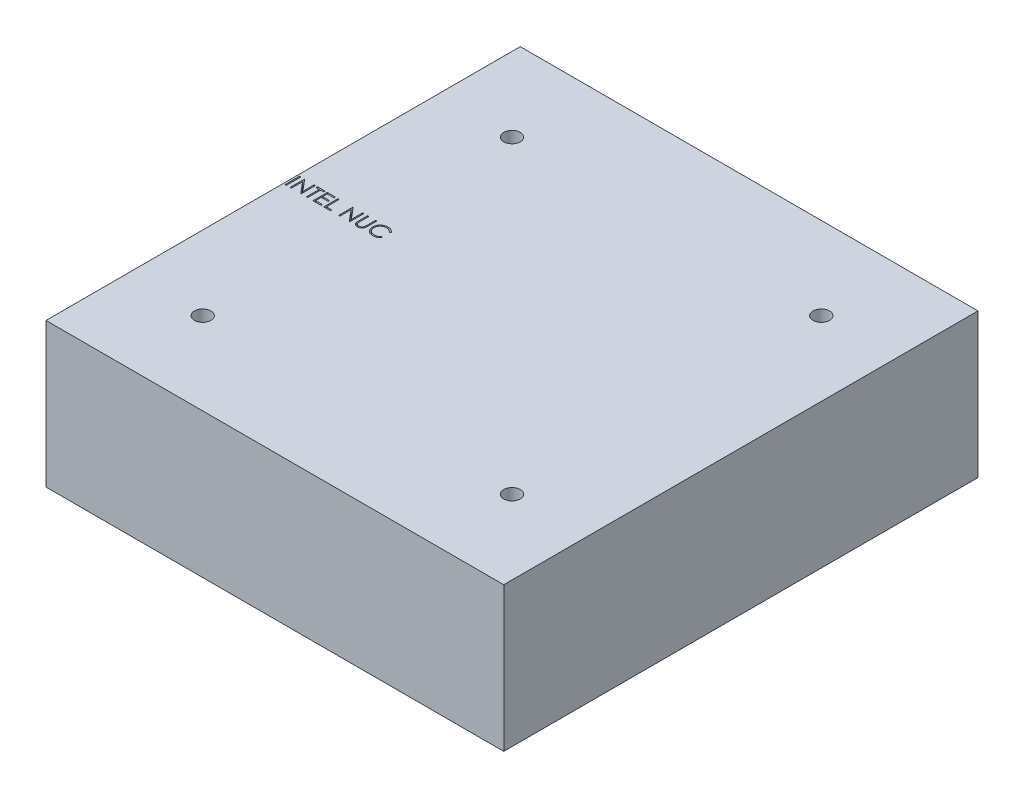
from build123d import *

# Parameters (mm, degrees)
SKETCH1_W           = 111
SKETCH1_H           = 115
BOSS_EXTRUDE1_DEPTH = 35
SKETCH2_R           = 2
CUT_EXTRUDE1_DEPTH  = 36
SKETCH3_W           = 0.314102564
SKETCH3_H           = 3.5
CUT_EXTRUDE2_DEPTH  = 36


with BuildPart() as part:
    # Sketch1 → Boss-Extrude1 (new body)
    with BuildSketch(Plane(origin=(0, 0, 0), x_dir=(1, 0, 0), z_dir=(0, 1, 0))):
        with Locations((55.5, 57.5)):
            Rectangle(SKETCH1_W, SKETCH1_H)
    extrude(amount=BOSS_EXTRUDE1_DEPTH)

    # Sketch2 → Cut-Extrude1 (cut, through all)
    with BuildSketch(Plane.XZ):
        with Locations((18, -20)):
            Circle(SKETCH2_R)
        with Locations((18, -95)):
            Circle(SKETCH2_R)
        with Locations((93, -20)):
            Circle(SKETCH2_R)
        with Locations((93, -95)):
            Circle(SKETCH2_R)
    extrude(amount=-CUT_EXTRUDE1_DEPTH, mode=Mode.SUBTRACT)

    # Sketch3 → Cut-Extrude2 (cut, through all)
    with BuildSketch(Plane(origin=(0, 35, 0), x_dir=(1, 0, 0), z_dir=(0, 1, 0))):
        with Locations((0.605769231, 59.25)):
            Rectangle(SKETCH3_W, SKETCH3_H)
        Polygon((1.66025641, 57.5), (1.66025641, 61), (1.726161859, 61), (4.038461538, 58.245292468), (4.038461538, 61), (4.352564103, 61), (4.352564103, 57.5), (4.281049679, 57.5), (1.974358974, 60.248397436), (1.974358974, 57.5), align=None)
        Polygon((4.846153846, 60.641025641), (4.846153846, 61), (6.685897436, 61), (6.685897436, 60.641025641), (5.923076923, 60.641025641), (5.923076923, 57.5), (5.608974359, 57.5), (5.608974359, 60.641025641), align=None)
        Polygon((7.224358974, 61), (9.198717949, 61), (9.198717949, 60.641025641), (7.538461538, 60.641025641), (7.538461538, 59.564102564), (9.198717949, 59.564102564), (9.198717949, 59.205128205), (7.538461538, 59.205128205), (7.538461538, 57.858974359), (9.198717949, 57.858974359), (9.198717949, 57.5), (7.224358974, 57.5), align=None)
        Polygon((9.826923077, 61), (10.141025641, 61), (10.141025641, 57.858974359), (11.487179487, 57.858974359), (11.487179487, 57.5), (9.826923077, 57.5), align=None)
        Polygon((13.416666667, 57.5), (13.416666667, 61), (13.482572115, 61), (15.794871795, 58.245292468), (15.794871795, 61), (16.108974359, 61), (16.108974359, 57.5), (16.037459936, 57.5), (13.730769231, 60.248397436), (13.730769231, 57.5), align=None)
        with BuildLine():
            Line((17.006410256, 61), (17.320512821, 61))
            Line((17.320512821, 61), (17.320512821, 58.902944712))
            add(Edge.make_bspline(
                [(17.320512821, 58.902944712), (17.320466077, 58.873263976), (17.320377372, 58.816939665), (17.320969886, 58.736771364), (17.322629254, 58.665498905), (17.323675414, 58.602847558), (17.326002747, 58.54910481), (17.327900794, 58.5039795), (17.330341351, 58.467685297), (17.333274468, 58.446504371), (17.334535256, 58.43739984)],
                knots=[0, 0, 0, 0, 8.9042e-05, 0.000168973, 0.000240502, 0.000302917, 0.000356945, 0.000401866, 0.000438432, 0.000465999, 0.000465999, 0.000465999, 0.000465999], degree=3))
            add(Edge.make_bspline(
                [(17.334535256, 58.43739984), (17.339712715, 58.404553076), (17.349775902, 58.340710347), (17.375422279, 58.249802065), (17.41123978, 58.167870607), (17.453682823, 58.092359316), (17.509615434, 58.025369956), (17.57661897, 57.963658303), (17.657796738, 57.909686499), (17.748057344, 57.860335687), (17.845342581, 57.820670604), (17.944753848, 57.79067724), (18.044796827, 57.77239834), (18.111772992, 57.770281801), (18.145032051, 57.769230769)],
                knots=[0, 0, 0, 0, 9.971e-05, 0.000193801, 0.000282365, 0.000367504, 0.000452699, 0.000543015, 0.000639862, 0.000744331, 0.000851226, 0.000954377, 0.001055468, 0.001155185, 0.001155185, 0.001155185, 0.001155185], degree=3))
            add(Edge.make_bspline(
                [(18.145032051, 57.769230769), (18.173585792, 57.77030462), (18.230528354, 57.772446118), (18.315134784, 57.785707549), (18.397534893, 57.809608115), (18.478135573, 57.840447873), (18.553686557, 57.881195464), (18.624229999, 57.928266303), (18.687193933, 57.98347718), (18.744651931, 58.044577524), (18.794686867, 58.113517324), (18.838058009, 58.188795462), (18.873583938, 58.271544809), (18.891127463, 58.329699231), (18.900140224, 58.359575321)],
                knots=[0, 0, 0, 0, 8.5678e-05, 0.00017086, 0.000256092, 0.000342674, 0.000429242, 0.000513055, 0.000596556, 0.000679898, 0.000764179, 0.00085149, 0.000940054, 0.001033621, 0.001033621, 0.001033621, 0.001033621], degree=3))
            add(Edge.make_bspline(
                [(18.900140224, 58.359575321), (18.90314035, 58.371923895), (18.909825838, 58.399441495), (18.916072883, 58.445962785), (18.922579408, 58.500852149), (18.927093978, 58.564503962), (18.931495199, 58.636704935), (18.934128271, 58.717831192), (18.935345304, 58.807588153), (18.935707985, 58.870225315), (18.935897436, 58.902944712)],
                knots=[0, 0, 0, 0, 3.81e-05, 8.4902e-05, 0.000140649, 0.000203941, 0.000276279, 0.000357657, 0.000447412, 0.000545571, 0.000545571, 0.000545571, 0.000545571], degree=3))
            Line((18.935897436, 58.902944712), (18.935897436, 61))
            Line((18.935897436, 61), (19.25, 61))
            Line((19.25, 61), (19.25, 58.886117788))
            add(Edge.make_bspline(
                [(19.25, 58.886117788), (19.24974588, 58.84801941), (19.249249948, 58.773668107), (19.244949372, 58.664716748), (19.238092372, 58.561363766), (19.228404284, 58.46359527), (19.215567281, 58.371761111), (19.20129206, 58.285056342), (19.183112527, 58.20410335), (19.161879126, 58.128270932), (19.137605578, 58.056085419), (19.10616443, 57.987576804), (19.07073993, 57.920662404), (19.028725277, 57.856354295), (18.981513894, 57.794367742), (18.928062213, 57.735078667), (18.870138052, 57.677539621), (18.806778493, 57.623226555), (18.739027968, 57.573417878), (18.66708801, 57.529620107), (18.59151124, 57.492596489), (18.512494114, 57.462120565), (18.430002911, 57.439205966), (18.344035551, 57.42213081), (18.254396358, 57.412428513), (18.193431702, 57.410986582), (18.162560096, 57.41025641)],
                knots=[0, 0, 0, 0, 0.000114291, 0.000223047, 0.000327049, 0.000424998, 0.000517708, 0.000605194, 0.000688542, 0.000766455, 0.0008414, 0.000916717, 0.000992315, 0.001068354, 0.001146882, 0.001225836, 0.001307639, 0.001391671, 0.001475952, 0.001559641, 0.001643989, 0.001728103, 0.001813335, 0.001900511, 0.00199079, 0.002083404, 0.002083404, 0.002083404, 0.002083404], degree=3))
            add(Edge.make_bspline(
                [(18.162560096, 57.41025641), (18.128890994, 57.411041176), (18.062832335, 57.412580882), (17.965494267, 57.421403632), (17.872180071, 57.438022027), (17.781904194, 57.45918197), (17.695895697, 57.488365708), (17.613002253, 57.522463832), (17.534643571, 57.564341093), (17.459548443, 57.610934486), (17.389723687, 57.663359124), (17.325626284, 57.720499298), (17.267150413, 57.781439675), (17.215281717, 57.846840041), (17.169160832, 57.916191748), (17.129430619, 57.989690988), (17.095317375, 58.067309304), (17.077710807, 58.121262504), (17.068810096, 58.14853766)],
                knots=[0, 0, 0, 0, 0.000101022, 0.000198206, 0.000292839, 0.000385177, 0.00047608, 0.000565014, 0.000653769, 0.000742283, 0.000829923, 0.000915339, 0.000999643, 0.001082971, 0.00116542, 0.001249186, 0.001333332, 0.001419362, 0.001419362, 0.001419362, 0.001419362], degree=3))
            add(Edge.make_bspline(
                [(17.068810096, 58.14853766), (17.063632938, 58.167170235), (17.052403567, 58.207584704), (17.040378269, 58.274471192), (17.030269187, 58.35148611), (17.020763629, 58.438634728), (17.015154671, 58.535984595), (17.010237232, 58.643493511), (17.006375614, 58.761291472), (17.006398386, 58.843345988), (17.006410256, 58.886117788)],
                knots=[0, 0, 0, 0, 5.799e-05, 0.000125782, 0.000203619, 0.000291034, 0.000388694, 0.000496078, 0.000613919, 0.000742226, 0.000742226, 0.000742226, 0.000742226], degree=3))
            Line((17.006410256, 58.886117788), (17.006410256, 61))
        make_face()
        with BuildLine():
            Line((23.378205128, 60.357772436), (23.103365385, 60.147435897))
            add(Edge.make_bspline(
                [(23.103365385, 60.147435897), (23.083759496, 60.170801867), (23.044812049, 60.217218783), (22.982152847, 60.282398327), (22.916851204, 60.343463589), (22.848932083, 60.400705469), (22.777172963, 60.452122234), (22.703312165, 60.500393337), (22.626114119, 60.543661075), (22.519362385, 60.596124061), (22.379714537, 60.650870216), (22.203919697, 60.696773448), (22.020408599, 60.725994623), (21.895210999, 60.729159465), (21.831530449, 60.730769231)],
                knots=[0, 0, 0, 0, 9.1485e-05, 0.000181737, 0.000271024, 0.000359627, 0.000447979, 0.000535687, 0.000624217, 0.000713268, 0.000892422, 0.00107303, 0.001257466, 0.001448389, 0.001448389, 0.001448389, 0.001448389], degree=3))
            add(Edge.make_bspline(
                [(21.831530449, 60.730769231), (21.796447149, 60.730365268), (21.726606157, 60.729561092), (21.622957683, 60.718951967), (21.521244632, 60.704040757), (21.421533166, 60.681915434), (21.323950207, 60.653942815), (21.227857805, 60.620517401), (21.134647206, 60.579162561), (21.043028967, 60.533454301), (20.955249756, 60.481826856), (20.872194709, 60.425513504), (20.794166741, 60.365144408), (20.721104129, 60.300493302), (20.65293218, 60.231851341), (20.590144869, 60.158487), (20.532959459, 60.080634826), (20.480242434, 59.999321419), (20.433029701, 59.914783627), (20.393499821, 59.826708556), (20.358494699, 59.736604453), (20.330795456, 59.643453293), (20.30887094, 59.547910527), (20.293743276, 59.449719739), (20.283254805, 59.349086059), (20.282454628, 59.280876747), (20.282051282, 59.246494391)],
                knots=[0, 0, 0, 0, 0.000105206, 0.000209435, 0.000312261, 0.00041348, 0.000515565, 0.000616682, 0.000718413, 0.000821258, 0.000923708, 0.001023662, 0.001122111, 0.001219464, 0.00131614, 0.001412112, 0.001508869, 0.001605718, 0.001702691, 0.001799013, 0.001895107, 0.001992482, 0.002090281, 0.00218895, 0.002290387, 0.00239349, 0.00239349, 0.00239349, 0.00239349], degree=3))
            add(Edge.make_bspline(
                [(20.282051282, 59.246494391), (20.283313101, 59.194763071), (20.285790515, 59.093195486), (20.307838849, 58.944424876), (20.341343941, 58.801904202), (20.391559518, 58.66652436), (20.453478568, 58.536616002), (20.53171918, 58.414377148), (20.622335717, 58.297960584), (20.726610137, 58.190117636), (20.841015953, 58.091603911), (20.963763864, 58.004853329), (21.094548152, 57.932538447), (21.231924782, 57.8723625), (21.376950896, 57.826105772), (21.529365698, 57.793541649), (21.688837694, 57.772299468), (21.797807094, 57.77026578), (21.853265224, 57.769230769)],
                knots=[0, 0, 0, 0, 0.000155106, 0.000304531, 0.000450265, 0.000593548, 0.000736853, 0.000881182, 0.001028026, 0.001178769, 0.001330408, 0.001480379, 0.001628835, 0.001777978, 0.001929641, 0.002084627, 0.002245075, 0.00241136, 0.00241136, 0.00241136, 0.00241136], degree=3))
            add(Edge.make_bspline(
                [(21.853265224, 57.769230769), (21.914367913, 57.770919549), (22.034632622, 57.774243472), (22.211000649, 57.802402721), (22.379836414, 57.848060638), (22.541149001, 57.911958561), (22.694483647, 57.995023849), (22.840080307, 58.095721726), (22.978061878, 58.215010059), (23.06103316, 58.306093187), (23.103365385, 58.352564103)],
                knots=[0, 0, 0, 0, 0.00018322, 0.00036062, 0.000534275, 0.000707044, 0.000879893, 0.001056289, 0.001237208, 0.001425665, 0.001425665, 0.001425665, 0.001425665], degree=3))
            Line((23.103365385, 58.352564103), (23.378205128, 58.144330929))
            add(Edge.make_bspline(
                [(23.378205128, 58.144330929), (23.356087018, 58.115792478), (23.311956743, 58.058852271), (23.240498726, 57.978580562), (23.165221429, 57.903076526), (23.085565719, 57.832948905), (23.002447927, 57.766794439), (22.914375615, 57.706492608), (22.822506582, 57.651201724), (22.727152103, 57.600574799), (22.628413491, 57.555657552), (22.526409056, 57.517203784), (22.42157848, 57.484078895), (22.313916972, 57.456826958), (22.203201215, 57.435555874), (22.089830741, 57.421336199), (21.973560866, 57.411594285), (21.895119444, 57.410706369), (21.85536859, 57.41025641)],
                knots=[0, 0, 0, 0, 0.000108293, 0.000216068, 0.000322162, 0.000427957, 0.000534281, 0.00064066, 0.000747915, 0.000855806, 0.000964371, 0.001073102, 0.001182643, 0.001294024, 0.001406092, 0.001520624, 0.001636667, 0.001755891, 0.001755891, 0.001755891, 0.001755891], degree=3))
            add(Edge.make_bspline(
                [(21.85536859, 57.41025641), (21.817724923, 57.410518403), (21.743289233, 57.411036461), (21.633390481, 57.419428628), (21.5264009, 57.430878365), (21.422626274, 57.448118496), (21.321500299, 57.468462836), (21.223939715, 57.495734093), (21.128984504, 57.526283259), (21.037016164, 57.562188246), (20.947956464, 57.602704429), (20.862092653, 57.648495987), (20.77946422, 57.699177852), (20.699258799, 57.753632863), (20.622661216, 57.813610164), (20.54900769, 57.878276799), (20.477885214, 57.94741481), (20.433882529, 57.997269663), (20.411758814, 58.022335737)],
                knots=[0, 0, 0, 0, 0.0001129, 0.000223246, 0.000330481, 0.000435603, 0.000538732, 0.000639764, 0.000739316, 0.000837878, 0.000935767, 0.001032686, 0.001129604, 0.00122645, 0.001323362, 0.001421241, 0.001520399, 0.001620667, 0.001620667, 0.001620667, 0.001620667], degree=3))
            add(Edge.make_bspline(
                [(20.411758814, 58.022335737), (20.376323171, 58.065876926), (20.305879694, 58.152433637), (20.21575401, 58.292719618), (20.138606455, 58.439187827), (20.076230534, 58.592607755), (20.027467801, 58.752635143), (19.993686606, 58.919350657), (19.971735002, 59.092598599), (19.969224713, 59.210435388), (19.967948718, 59.270332532)],
                knots=[0, 0, 0, 0, 0.000168306, 0.00033458, 0.000499224, 0.000664315, 0.00083066, 0.00100034, 0.001174094, 0.001353718, 0.001353718, 0.001353718, 0.001353718], degree=3))
            add(Edge.make_bspline(
                [(19.967948718, 59.270332532), (19.969503912, 59.333287986), (19.972563658, 59.45714891), (19.998559453, 59.638922863), (20.040378249, 59.813074262), (20.099775138, 59.979278007), (20.175080489, 60.138408287), (20.268107103, 60.289249492), (20.377774245, 60.432766292), (20.503221813, 60.566781043), (20.640789148, 60.689320396), (20.788107962, 60.797126599), (20.944889909, 60.886844115), (21.109407761, 60.961840278), (21.282893442, 61.019484741), (21.464976812, 61.059837928), (21.655315726, 61.084955044), (21.785178152, 61.088130252), (21.851161859, 61.08974359)],
                knots=[0, 0, 0, 0, 0.000188789, 0.000371431, 0.000549644, 0.000725278, 0.00089996, 0.001076844, 0.001255917, 0.001440951, 0.001626689, 0.001807878, 0.001987546, 0.002167657, 0.002349462, 0.002534866, 0.002726448, 0.002924344, 0.002924344, 0.002924344, 0.002924344], degree=3))
            add(Edge.make_bspline(
                [(21.851161859, 61.08974359), (21.891376331, 61.089261452), (21.970976828, 61.088307108), (22.088729481, 61.079000965), (22.203371808, 61.063487359), (22.31498279, 61.042371289), (22.424105406, 61.016163968), (22.529905647, 60.98202367), (22.633004334, 60.942987138), (22.732751242, 60.898028672), (22.828667792, 60.847561931), (22.92072411, 60.792146307), (23.008188969, 60.731850502), (23.091677818, 60.667187326), (23.169794029, 60.596788767), (23.244755507, 60.522591171), (23.314016585, 60.442457347), (23.35676978, 60.386052413), (23.378205128, 60.357772436)],
                knots=[0, 0, 0, 0, 0.000120626, 0.000238766, 0.000354085, 0.000467531, 0.000579423, 0.000690512, 0.000800803, 0.000910007, 0.001018518, 0.001125773, 0.001232152, 0.001337058, 0.001442329, 0.001547432, 0.001653292, 0.001759736, 0.001759736, 0.001759736, 0.001759736], degree=3))
        make_face()
    extrude(amount=-CUT_EXTRUDE2_DEPTH, mode=Mode.SUBTRACT)


solid = part.part
